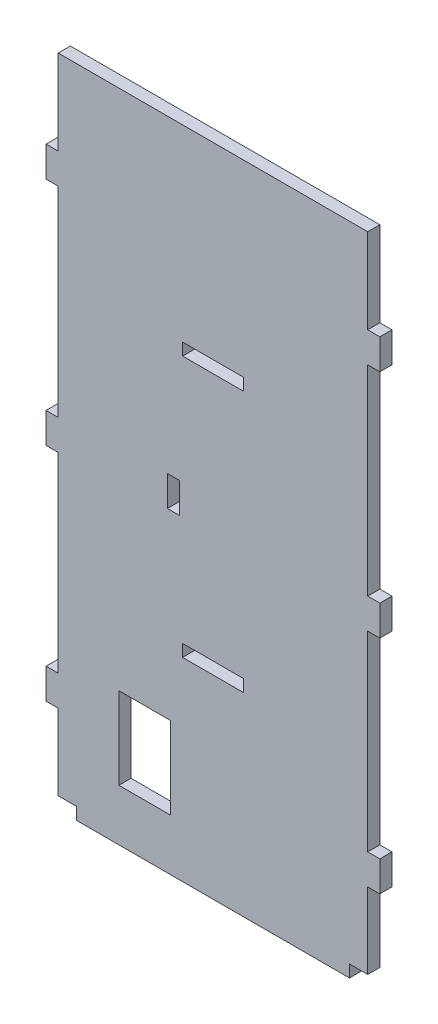
from build123d import *

# Parameters (mm, degrees)
SKETCH1_W           = 10
SKETCH1_H           = 2
SKETCH1_W_2         = 2
SKETCH1_H_2         = 5
SKETCH1_W_3         = 8.5
SKETCH1_H_3         = 13.5
BOSS_EXTRUDE1_DEPTH = 2


with BuildPart() as part:
    # Sketch1 → Boss-Extrude1 (new body)
    with BuildSketch(Plane.XY):
        Polygon((0, 0), (3, 0), (3, -2), (48, -2), (48, 0), (51, 0), (51, 12.5), (53, 12.5), (53, 17.5), (51, 17.5), (51, 49), (53, 49), (53, 54), (51, 54), (51, 87), (53, 87), (53, 92), (51, 92), (51, 106), (0, 106), (0, 92), (-2, 92), (-2, 87), (0, 87), (0, 54), (-2, 54), (-2, 49), (0, 49), (0, 17.5), (-2, 17.5), (-2, 12.5), (0, 12.5), align=None)
        with Locations((25.5, 31)):
            Rectangle(SKETCH1_W, SKETCH1_H, mode=Mode.SUBTRACT)
        with Locations((25.5, 74)):
            Rectangle(SKETCH1_W, SKETCH1_H, mode=Mode.SUBTRACT)
        with Locations((19, 52.5)):
            Rectangle(SKETCH1_W_2, SKETCH1_H_2, mode=Mode.SUBTRACT)
        with Locations((14.25, 13.25)):
            Rectangle(SKETCH1_W_3, SKETCH1_H_3, mode=Mode.SUBTRACT)
    extrude(amount=BOSS_EXTRUDE1_DEPTH)


solid = part.part
